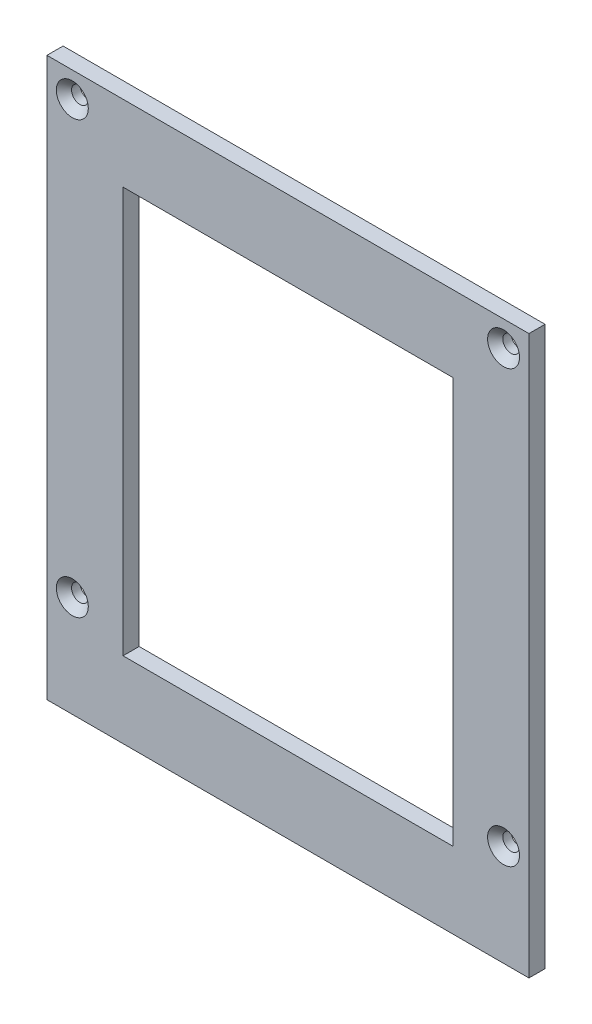
from build123d import *

# Parameters (mm, degrees)
SKETCH1_W                                           = 190
SKETCH1_H                                           = 220
SKETCH1_W_2                                         = 130
SKETCH1_H_2                                         = 160
BOSS_EXTRUDE1_DEPTH                                 = 6.35
CSK_FOR_M6_COUNTERSUNK_FLAT_HEAD_SCREW1_D           = 6.6
CSK_FOR_M6_COUNTERSUNK_FLAT_HEAD_SCREW1_DEPTH       = 45
CSK_FOR_M6_COUNTERSUNK_FLAT_HEAD_SCREW1_CSINK_D     = 12.5984
CSK_FOR_M6_COUNTERSUNK_FLAT_HEAD_SCREW1_CSINK_ANGLE = 90
CSK_FOR_M6_COUNTERSUNK_FLAT_HEAD_SCREW1_TIP         = 1.982840043


with BuildPart() as part:
    # Sketch1 → Boss-Extrude1 (new body)
    with BuildSketch(Plane.XY):
        Rectangle(SKETCH1_W, SKETCH1_H)
        Rectangle(SKETCH1_W_2, SKETCH1_H_2, mode=Mode.SUBTRACT)
    extrude(amount=BOSS_EXTRUDE1_DEPTH)

    # CSK for M6 Countersunk Flat Head Screw1
    with Locations(Plane.XY.offset(6.35)):
        with Locations((-85, -70), (-85, 100), (85, 100), (85, -70)):
            CounterSinkHole(CSK_FOR_M6_COUNTERSUNK_FLAT_HEAD_SCREW1_D / 2, CSK_FOR_M6_COUNTERSUNK_FLAT_HEAD_SCREW1_CSINK_D / 2, depth=CSK_FOR_M6_COUNTERSUNK_FLAT_HEAD_SCREW1_DEPTH, counter_sink_angle=CSK_FOR_M6_COUNTERSUNK_FLAT_HEAD_SCREW1_CSINK_ANGLE)
            with Locations((0, 0, -(CSK_FOR_M6_COUNTERSUNK_FLAT_HEAD_SCREW1_DEPTH + CSK_FOR_M6_COUNTERSUNK_FLAT_HEAD_SCREW1_TIP / 2))):  # 118° drill point
                Cone(0, CSK_FOR_M6_COUNTERSUNK_FLAT_HEAD_SCREW1_D / 2, CSK_FOR_M6_COUNTERSUNK_FLAT_HEAD_SCREW1_TIP, mode=Mode.SUBTRACT)


solid = part.part
